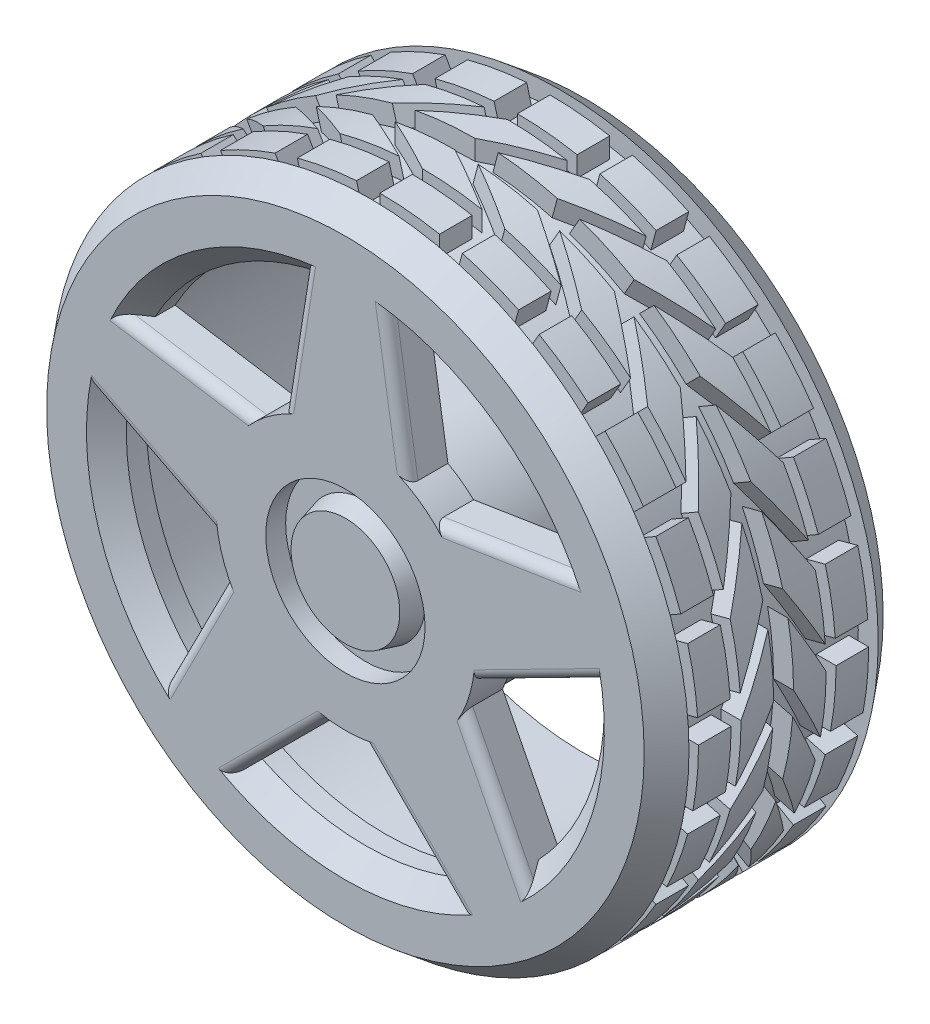
from build123d import *

# Parameters (mm, degrees)
SKETCH2_W           = 10.386040433
SKETCH2_H           = 19.05
BOSS_EXTRUDE1_DEPTH = 9.525
CIRPATTERN1_COUNT   = 24
SKETCH3_R           = 85.725
SKETCH3_R_2         = 38.1
CUT_EXTRUDE1_DEPTH  = 63.5
SKETCH4_R           = 103.370510785
SKETCH4_R_2         = 101.6
CUT_EXTRUDE2_DEPTH  = 76.2
BOSS_EXTRUDE2_REACH = 78.2
SKETCH5_R           = 25.4
CUT_EXTRUDE3_DEPTH  = 6.35
FILLET1_R           = 3.175
SKETCH7_R           = 19.05
BOSS_EXTRUDE3_DEPTH = 6.35
BOSS_EXTRUDE3_TAPER = 15


with BuildPart() as part:
    # Sketch1 → Revolve2 (revolve)
    with BuildSketch(Plane(origin=(0, 0, 0), x_dir=(0, 0, -1), z_dir=(1, 0, 0))):
        Polygon((38.1, 95.25), (38.1, 25.4), (-19.05, 25.4), (-19.05, 0), (-31.75, 0), (-31.75, 25.4), (-31.75, 76.2), (-38.1, 82.55), (-38.1, 95.25), (-30.1625, 101.6), (-30.1625, 95.25), (30.1625, 95.25), (30.1625, 101.6), align=None)
    revolve(axis=Axis((0, 0, 38.1), (0, 0, -1)))

    # Sketch2 → Boss-Extrude1 (add)
    with BuildSketch(Plane(origin=(101.6, 0, 0), x_dir=(0, 0, -1), z_dir=(1, 0, 0))):
        with Locations((-21.92906065, -9.525)):
            Rectangle(SKETCH2_W, SKETCH2_H)
        Polygon((-13.561040434, -19.05), (-13.561040434, 0), (-3.175, 19.05), (-3.175, 0), align=None)
        with Locations((21.92906065, -9.525)):
            Rectangle(SKETCH2_W, SKETCH2_H)
        Polygon((3.175, 0), (3.175, 19.05), (13.561040434, 0), (13.561040434, -19.05), align=None)
    boss_extrude1 = extrude(amount=-BOSS_EXTRUDE1_DEPTH)

    # CirPattern1: Boss-Extrude1 ×24 about axis
    cirpattern1_axis = Axis((0, 0, 0), (0, 0, 1))
    for i in range(1, CIRPATTERN1_COUNT):
        add(boss_extrude1.rotate(cirpattern1_axis, i * 360 / CIRPATTERN1_COUNT))

    # Sketch3 → Cut-Extrude1 (cut)
    with BuildSketch(Plane(origin=(0, 0, -38.1), x_dir=(-1, 0, 0), z_dir=(0, 0, -1))):
        Circle(SKETCH3_R)
        Circle(SKETCH3_R_2, mode=Mode.SUBTRACT)
    extrude(amount=-CUT_EXTRUDE1_DEPTH, mode=Mode.SUBTRACT)

    # Sketch4 → Cut-Extrude2 (cut)
    with BuildSketch(Plane.XY.offset(38.1)):
        Circle(SKETCH4_R)
        Circle(SKETCH4_R_2, mode=Mode.SUBTRACT)
    extrude(amount=-CUT_EXTRUDE2_DEPTH, mode=Mode.SUBTRACT)

    # Sketch5 → Boss-Extrude2 (add, up to next)
    with BuildSketch(Plane.XY.offset(38.1), mode=Mode.PRIVATE) as boss_extrude2_sk1:
        with BuildLine():
            Line((19.985880502, 36.113573702), (12.782417909, 81.554351769))
            ThreePointArc((12.782417909, 81.554351769), (0, 82.55), (-12.782417909, 81.554351769))
            Line((-12.782417909, 81.554351769), (-19.985880502, 36.113573702))
            ThreePointArc((-19.985880502, 36.113573702), (-24.260836288, 33.392176443), (-28.170072874, 30.167409887))
            Line((-28.170072874, 30.167409887), (-73.612813319, 37.358482508))
            ThreePointArc((-73.612813319, 37.358482508), (-78.50971542, 25.509352886), (-81.512782045, 13.044878816))
            Line((-81.512782045, 13.044878816), (-40.522026319, -7.847993884))
            ThreePointArc((-40.522026319, -7.847993884), (-39.25485771, -12.754676443), (-37.395943004, -17.46908904))
            Line((-37.395943004, -17.46908904), (-58.277638547, -58.465539811))
            ThreePointArc((-58.277638547, -58.465539811), (-48.521672577, -66.784352886), (-37.595251912, -73.492173281))
            Line((-37.595251912, -73.492173281), (-5.058109056, -40.963900666))
            ThreePointArc((-5.058109056, -40.963900666), (0, -41.275), (5.058109056, -40.963900666))
            Line((5.058109056, -40.963900666), (37.595251912, -73.492173281))
            ThreePointArc((37.595251912, -73.492173281), (48.521672577, -66.784352886), (58.277638547, -58.465539811))
            Line((58.277638547, -58.465539811), (37.395943004, -17.46908904))
            ThreePointArc((37.395943004, -17.46908904), (39.25485771, -12.754676443), (40.522026319, -7.847993884))
            Line((40.522026319, -7.847993884), (81.512782045, 13.044878816))
            ThreePointArc((81.512782045, 13.044878816), (78.50971542, 25.509352886), (73.612813319, 37.358482508))
            Line((73.612813319, 37.358482508), (28.170072874, 30.167409887))
            ThreePointArc((28.170072874, 30.167409887), (24.260836288, 33.392176443), (19.985880502, 36.113573702))
        make_face()
        Circle(SKETCH5_R, mode=Mode.SUBTRACT)
    boss_extrude2_tool1 = extrude(boss_extrude2_sk1.sketch, amount=-BOSS_EXTRUDE2_REACH, mode=Mode.PRIVATE) - part.part
    add(boss_extrude2_tool1.solids().sort_by_distance((-22.922184, -55.632099, 38.1))[0])

    # Sketch6 → Cut-Extrude3 (cut)
    with BuildSketch(Plane.XY.offset(31.75)):
        with BuildLine():
            Line((28.170072874, 30.167409887), (66.992272438, 36.310817033))
            ThreePointArc((66.992272438, 36.310817033), (44.789236225, 61.647094971), (13.831888476, 74.934096786))
            Line((13.831888476, 74.934096786), (19.985880502, 36.113573702))
            ThreePointArc((19.985880502, 36.113573702), (24.260836288, 33.392176443), (28.170072874, 30.167409887))
        make_face()
        with BuildLine():
            Line((75.540849645, 10.001001698), (40.522026319, -7.847993884))
            ThreePointArc((40.522026319, -7.847993884), (39.25485771, -12.754676443), (37.395943004, -17.46908904))
            Line((37.395943004, -17.46908904), (55.235389826, -52.492777701))
            ThreePointArc((55.235389826, -52.492777701), (72.470506542, -23.547094971), (75.540849645, 10.001001698))
        make_face()
        with BuildLine():
            Line((32.854924144, -68.753137816), (5.058109056, -40.963900666))
            ThreePointArc((5.058109056, -40.963900666), (0, -41.275), (-5.058109056, -40.963900666))
            Line((-5.058109056, -40.963900666), (-32.854924144, -68.753137816))
            ThreePointArc((-32.854924144, -68.753137816), (0, -76.2), (32.854924144, -68.753137816))
        make_face()
        with BuildLine():
            Line((-55.235389826, -52.492777701), (-37.395943004, -17.46908904))
            ThreePointArc((-37.395943004, -17.46908904), (-39.25485771, -12.754676443), (-40.522026319, -7.847993884))
            Line((-40.522026319, -7.847993884), (-75.540849645, 10.001001698))
            ThreePointArc((-75.540849645, 10.001001698), (-72.470506542, -23.547094971), (-55.235389826, -52.492777701))
        make_face()
        with BuildLine():
            Line((-66.992272438, 36.310817033), (-28.170072874, 30.167409887))
            ThreePointArc((-28.170072874, 30.167409887), (-24.260836288, 33.392176443), (-19.985880502, 36.113573702))
            Line((-19.985880502, 36.113573702), (-13.831888476, 74.934096786))
            ThreePointArc((-13.831888476, 74.934096786), (-44.789236225, 61.647094971), (-66.992272438, 36.310817033))
        make_face()
    extrude(amount=-CUT_EXTRUDE3_DEPTH, mode=Mode.SUBTRACT)

    # Fillet1
    fillet1_edges = [part.edges().sort_by_distance(p)[0] for p in [
        (16.384149205, 58.833962736, 38.1),
        (-16.384149205, 58.833962736, 38.1),
        (50.891443096, 33.762946197, 38.1),
        (61.017404182, 2.598442466, 38.1),
        (47.836790775, -37.967314425, 38.1),
        (21.326680484, -57.228036974, 38.1),
        (-21.326680484, -57.228036974, 38.1),
        (-47.836790775, -37.967314425, 38.1),
        (-61.017404182, 2.598442466, 38.1),
        (-50.891443096, 33.762946197, 38.1),
    ]]
    fillet(fillet1_edges, radius=FILLET1_R)

    # Sketch7 → Boss-Extrude3 (add)
    with BuildSketch(Plane.XY.offset(31.75)):
        Circle(SKETCH7_R)
    extrude(amount=BOSS_EXTRUDE3_DEPTH, taper=BOSS_EXTRUDE3_TAPER)


solid = part.part
